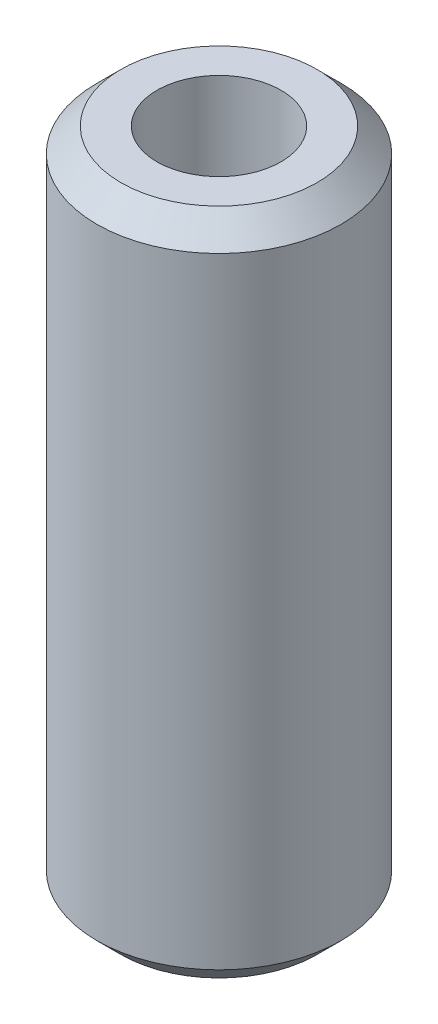
from build123d import *


with BuildPart() as part:
    # Sketch1 → Revolve1 (revolve)
    with BuildSketch(Plane.XY):
        Polygon((12.7, 32.25), (12.7, -32.25), (10.2, -34.75), (6.45, -34.75), (6.45, 34.75), (10.2, 34.75), align=None)
    revolve(axis=Axis((0, 78.808165711, 0), (0, -1, 0)))


solid = part.part
